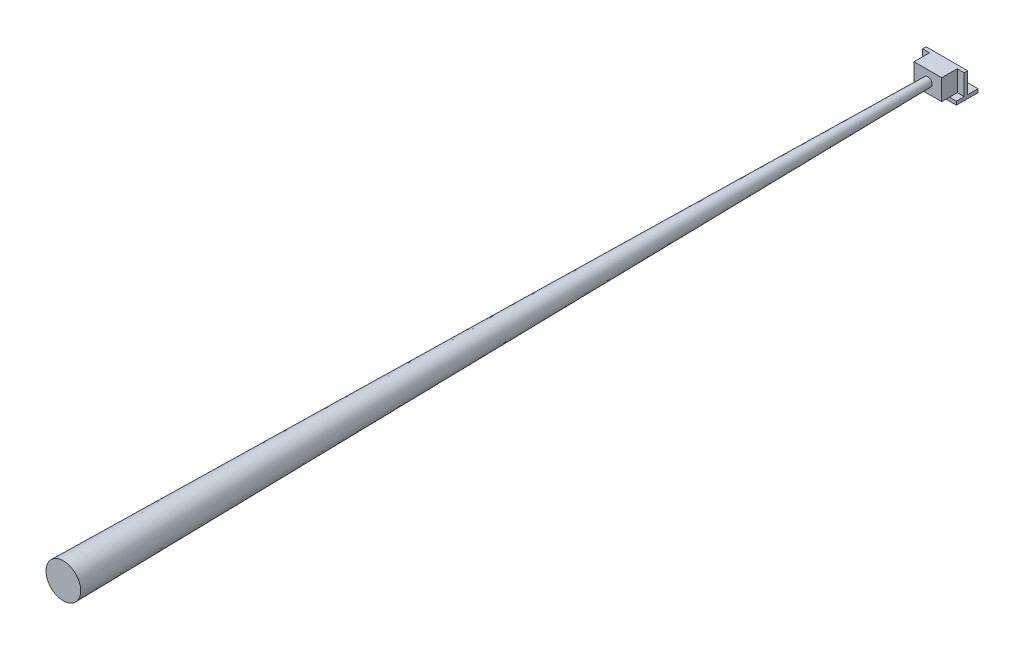
from build123d import *

# Parameters (mm, degrees)
SKETCH1_W           = 48
SKETCH1_H           = 25
BOSS_EXTRUDE1_DEPTH = 4
BOSS_EXTRUDE2_DEPTH = 24
CUT_EXTRUDE1_REACH  = 42.178
SKETCH2_4_R         = 1.6


with BuildPart() as part:
    # Sketch1 → Boss-Extrude1 (new body)
    with BuildSketch(Plane(origin=(0, 0, 0), x_dir=(1, 0, 0), z_dir=(0, 1, 0))):
        Rectangle(SKETCH1_W, SKETCH1_H)
    extrude(amount=BOSS_EXTRUDE1_DEPTH)

    # Sketch2 → Boss-Extrude2 (add)
    with BuildSketch(Plane(origin=(0, 4, 0), x_dir=(1, 0, 0), z_dir=(0, 1, 0))):
        Polygon((24, 0.5), (-24, 0.5), (-24, -3.5), (-16, -3.5), (-16, -21.5), (16, -21.5), (16, -3.5), (24, -3.5), align=None)
    extrude(amount=BOSS_EXTRUDE2_DEPTH)

    # Sketch2_4 → Cut-Extrude1 (cut, up to next)
    with BuildSketch(Plane(origin=(0, 4, 0), x_dir=(1, 0, 0), z_dir=(0, 1, 0)), mode=Mode.PRIVATE) as cut_extrude1_sk1:
        with Locations((0, 7.5)):
            Circle(SKETCH2_4_R)
    cut_extrude1_tool1 = extrude(cut_extrude1_sk1.sketch, amount=-CUT_EXTRUDE1_REACH, mode=Mode.PRIVATE) & part.part
    # Sketch2_4 → Cut-Extrude1 (cut, up to next)
    with BuildSketch(Plane(origin=(0, 4, 0), x_dir=(1, 0, 0), z_dir=(0, 1, 0)), mode=Mode.PRIVATE) as cut_extrude1_sk2:
        with Locations((-10, 7.5)):
            Circle(SKETCH2_4_R)
    cut_extrude1_tool2 = extrude(cut_extrude1_sk2.sketch, amount=-CUT_EXTRUDE1_REACH, mode=Mode.PRIVATE) & part.part
    # Sketch2_4 → Cut-Extrude1 (cut, up to next)
    with BuildSketch(Plane(origin=(0, 4, 0), x_dir=(1, 0, 0), z_dir=(0, 1, 0)), mode=Mode.PRIVATE) as cut_extrude1_sk3:
        with Locations((10, 7.5)):
            Circle(SKETCH2_4_R)
    cut_extrude1_tool3 = extrude(cut_extrude1_sk3.sketch, amount=-CUT_EXTRUDE1_REACH, mode=Mode.PRIVATE) & part.part
    add(cut_extrude1_tool1.solids().sort_by_distance((0, 4, -7.5))[0], mode=Mode.SUBTRACT)
    add(cut_extrude1_tool2.solids().sort_by_distance((-10, 4, -7.5))[0], mode=Mode.SUBTRACT)
    add(cut_extrude1_tool3.solids().sort_by_distance((10, 4, -7.5))[0], mode=Mode.SUBTRACT)


with BuildPart() as body_2:
    # Sketch3 → Revolve1 (revolve)
    with BuildSketch(Plane(origin=(0, 0, 0), x_dir=(0, 0, -1), z_dir=(1, 0, 0))):
        Polygon((-1021.5, 36.073982115), (-1021.5, 16), (-21.5, 16), (-21.5, 21), align=None)
    revolve(axis=Axis((0, 16, 1021.5), (0, 0, -1)))


solid = Compound([part.part, body_2.part])
